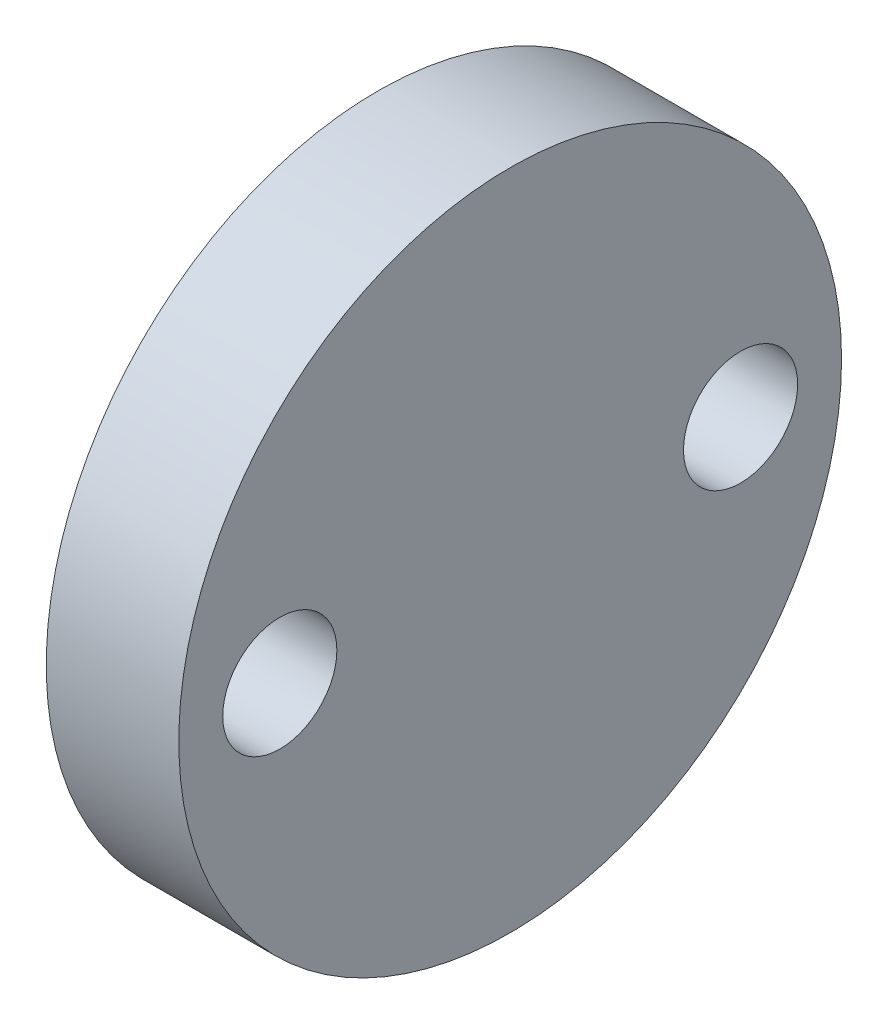
from build123d import *

# Parameters (mm, degrees)
SKETCH1_R                        = 12.5
BOSS_EXTRUDE1_DEPTH              = 5
F_18_0_1695_DIAMETER_HOLE2_D     = 4.3053
F_18_0_1695_DIAMETER_HOLE2_DEPTH = 10.1092
F_18_0_1695_DIAMETER_HOLE2_TIP   = 1.293442612


with BuildPart() as part:
    # Sketch1 → Boss-Extrude1 (new body)
    with BuildSketch(Plane(origin=(0, 0, 0), x_dir=(0, 0, -1), z_dir=(1, 0, 0))):
        Circle(SKETCH1_R)
    extrude(amount=BOSS_EXTRUDE1_DEPTH)

    # #18 (0.1695) Diameter Hole2
    with Locations(Plane.ZY):
        with Locations((-8.69, 0), (8.69, 0)):
            Hole(F_18_0_1695_DIAMETER_HOLE2_D / 2, depth=F_18_0_1695_DIAMETER_HOLE2_DEPTH)
            with Locations((0, 0, -(F_18_0_1695_DIAMETER_HOLE2_DEPTH + F_18_0_1695_DIAMETER_HOLE2_TIP / 2))):  # 118° drill point
                Cone(0, F_18_0_1695_DIAMETER_HOLE2_D / 2, F_18_0_1695_DIAMETER_HOLE2_TIP, mode=Mode.SUBTRACT)


solid = part.part
